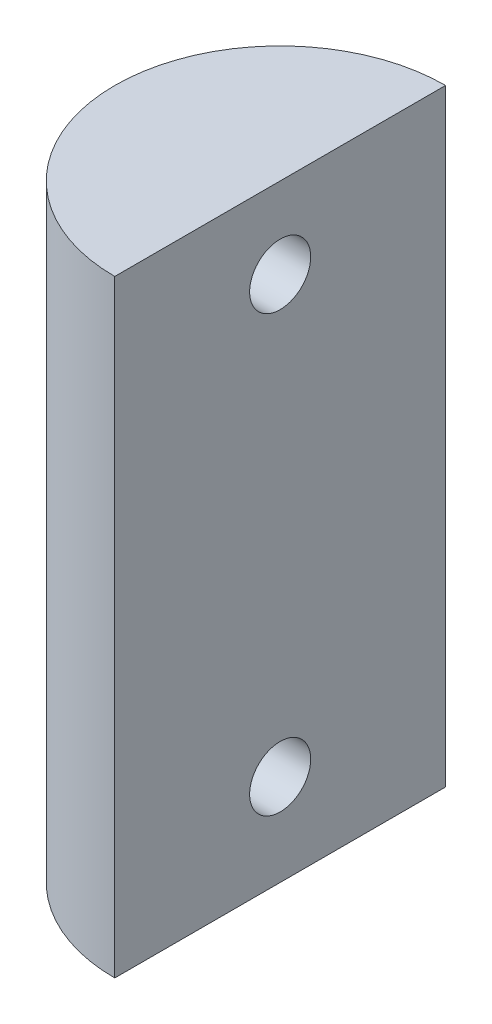
from build123d import *

# Parameters (mm, degrees)
BOSS_EXTRUDE1_DEPTH = 119.376
SKETCH2_R           = 6
CUT_EXTRUDE1_DEPTH  = 56
SKETCH3_R           = 6
CUT_EXTRUDE2_DEPTH  = 56


with BuildPart() as part:
    # Sketch1 → Boss-Extrude1 (new body)
    with BuildSketch(Plane(origin=(0, 0, 0), x_dir=(1, 0, 0), z_dir=(0, 1, 0))):
        with BuildLine():
            Line((0, -32.5), (0, 32.5))
            ThreePointArc((0, 32.5), (-32.5, 0), (0, -32.5))
        make_face()
    extrude(amount=-BOSS_EXTRUDE1_DEPTH)

    # Sketch2 → Cut-Extrude1 (cut)
    with BuildSketch(Plane(origin=(0, 0, 0), x_dir=(0, 0, -1), z_dir=(1, 0, 0))):
        with Locations((0, -15.894)):
            Circle(SKETCH2_R)
    extrude(amount=-CUT_EXTRUDE1_DEPTH, mode=Mode.SUBTRACT)

    # Sketch3 → Cut-Extrude2 (cut)
    with BuildSketch(Plane(origin=(0, 0, 0), x_dir=(0, 0, -1), z_dir=(1, 0, 0))):
        with Locations((0, -101.376)):
            Circle(SKETCH3_R)
    extrude(amount=-CUT_EXTRUDE2_DEPTH, mode=Mode.SUBTRACT)


solid = part.part
